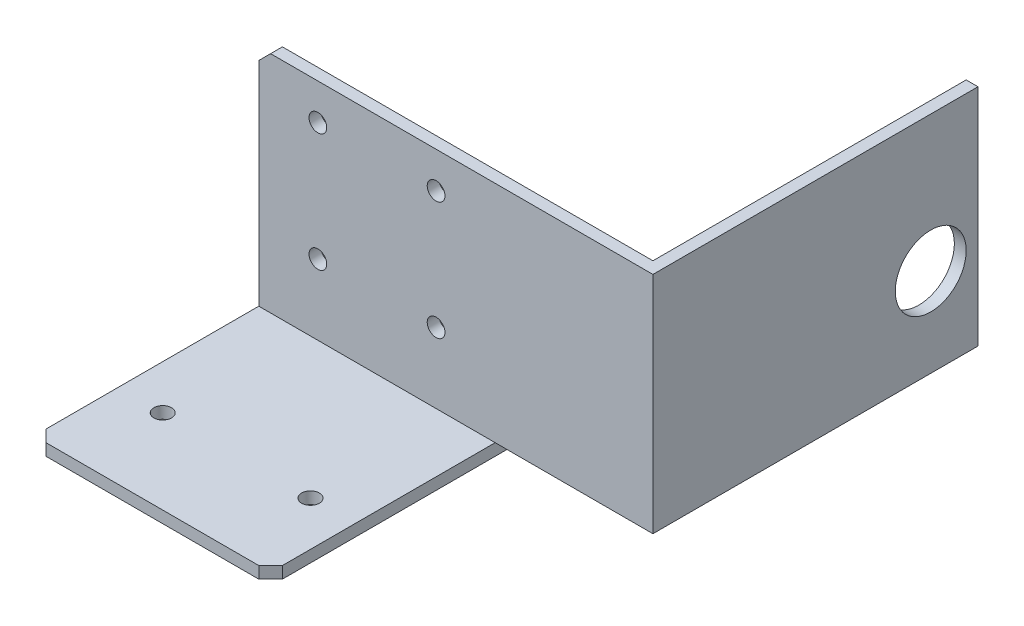
from build123d import *

# Parameters (mm, degrees)
EXTRUDE1_DEPTH           = 40
EXTRUDE2_REACH           = 42
SKETCH2_R                = 1.5
EXTRUDE3_REACH           = 42
SKETCH3_R                = 1.5
CHAMFER1_SIZE            = 2
SKETCH4_W                = 2
SKETCH4_H                = 38
BOSS_EXTRUDE1_DEPTH      = 26.69
BOSS_EXTRUDE1_DEPTH_BACK = 3
SKETCH5_W                = 53
SKETCH5_H                = 38
BOSS_EXTRUDE2_DEPTH      = 2
SKETCH6_R                = 6
CUT_EXTRUDE1_DEPTH       = 3


with BuildPart() as part:
    # Sketch1 → Extrude1 (new body)
    with BuildSketch(Plane(origin=(0, 0, 0), x_dir=(0, 0, -1), z_dir=(1, 0, 0))):
        Polygon((0, 0), (0, 38), (2, 38), (2, -2), (-38, -2), (-38, 0), align=None)
    extrude(amount=EXTRUDE1_DEPTH)

    # Sketch2 → Extrude2 (cut, up to next)
    with BuildSketch(Plane(origin=(0, -2, 0), x_dir=(-1, 0, 0), z_dir=(0, -1, 0)), mode=Mode.PRIVATE) as extrude2_sk1:
        with Locations((-32.5, -23.75)):
            Circle(SKETCH2_R)
    extrude2_tool1 = extrude(extrude2_sk1.sketch, amount=-EXTRUDE2_REACH, mode=Mode.PRIVATE) & part.part
    add(extrude2_tool1.solids().sort_by_distance((32.5, -2, 23.75))[0], mode=Mode.SUBTRACT)
    # Sketch2 → Extrude2 (cut, up to next)
    with BuildSketch(Plane(origin=(0, -2, 0), x_dir=(-1, 0, 0), z_dir=(0, -1, 0)), mode=Mode.PRIVATE) as extrude2_sk2:
        with Locations((-7.5, -23.75)):
            Circle(SKETCH2_R)
    extrude2_tool2 = extrude(extrude2_sk2.sketch, amount=-EXTRUDE2_REACH, mode=Mode.PRIVATE) & part.part
    add(extrude2_tool2.solids().sort_by_distance((7.5, -2, 23.75))[0], mode=Mode.SUBTRACT)

    # Sketch3 → Extrude3 (cut, up to next)
    with BuildSketch(Plane(origin=(0, 0, -2), x_dir=(-1, 0, 0), z_dir=(0, 0, -1)), mode=Mode.PRIVATE) as extrude3_sk1:
        with Locations((-10, 31.9)):
            Circle(SKETCH3_R)
    extrude3_tool1 = extrude(extrude3_sk1.sketch, amount=-EXTRUDE3_REACH, mode=Mode.PRIVATE) & part.part
    add(extrude3_tool1.solids().sort_by_distance((10, 31.9, -2))[0], mode=Mode.SUBTRACT)
    # Sketch3 → Extrude3 (cut, up to next)
    with BuildSketch(Plane(origin=(0, 0, -2), x_dir=(-1, 0, 0), z_dir=(0, 0, -1)), mode=Mode.PRIVATE) as extrude3_sk2:
        with Locations((-30, 31.9)):
            Circle(SKETCH3_R)
    extrude3_tool2 = extrude(extrude3_sk2.sketch, amount=-EXTRUDE3_REACH, mode=Mode.PRIVATE) & part.part
    add(extrude3_tool2.solids().sort_by_distance((30, 31.9, -2))[0], mode=Mode.SUBTRACT)
    # Sketch3 → Extrude3 (cut, up to next)
    with BuildSketch(Plane(origin=(0, 0, -2), x_dir=(-1, 0, 0), z_dir=(0, 0, -1)), mode=Mode.PRIVATE) as extrude3_sk3:
        with Locations((-30, 11.9)):
            Circle(SKETCH3_R)
    extrude3_tool3 = extrude(extrude3_sk3.sketch, amount=-EXTRUDE3_REACH, mode=Mode.PRIVATE) & part.part
    add(extrude3_tool3.solids().sort_by_distance((30, 11.9, -2))[0], mode=Mode.SUBTRACT)
    # Sketch3 → Extrude3 (cut, up to next)
    with BuildSketch(Plane(origin=(0, 0, -2), x_dir=(-1, 0, 0), z_dir=(0, 0, -1)), mode=Mode.PRIVATE) as extrude3_sk4:
        with Locations((-10, 11.9)):
            Circle(SKETCH3_R)
    extrude3_tool4 = extrude(extrude3_sk4.sketch, amount=-EXTRUDE3_REACH, mode=Mode.PRIVATE) & part.part
    add(extrude3_tool4.solids().sort_by_distance((10, 11.9, -2))[0], mode=Mode.SUBTRACT)

    # Chamfer1
    chamfer1_edges = [part.edges().sort_by_distance(p)[0] for p in [
        (40, 38, -1),
        (0, 38, -1),
        (40, -1, 38),
        (0, -1, 38),
    ]]
    chamfer(chamfer1_edges, length=CHAMFER1_SIZE)

    # Sketch4 → Boss-Extrude1 (add, two sides)
    with BuildSketch(Plane(origin=(40, 0, 0), x_dir=(0, 0, -1), z_dir=(1, 0, 0))) as boss_extrude1_sk:
        with Locations((1, 19)):
            Rectangle(SKETCH4_W, SKETCH4_H)
    extrude(amount=BOSS_EXTRUDE1_DEPTH)
    extrude(boss_extrude1_sk.sketch, amount=-BOSS_EXTRUDE1_DEPTH_BACK)

    # Sketch5 → Boss-Extrude2 (add)
    with BuildSketch(Plane(origin=(66.69, 0, 0), x_dir=(0, 0, -1), z_dir=(1, 0, 0))):
        with Locations((28.5, 19)):
            Rectangle(SKETCH5_W, SKETCH5_H)
    extrude(amount=-BOSS_EXTRUDE2_DEPTH)

    # Sketch6 → Cut-Extrude1 (cut)
    with BuildSketch(Plane(origin=(66.69, 0, 0), x_dir=(0, 0, -1), z_dir=(1, 0, 0))):
        with Locations((47, 15)):
            Circle(SKETCH6_R)
    extrude(amount=-CUT_EXTRUDE1_DEPTH, mode=Mode.SUBTRACT)


solid = part.part
